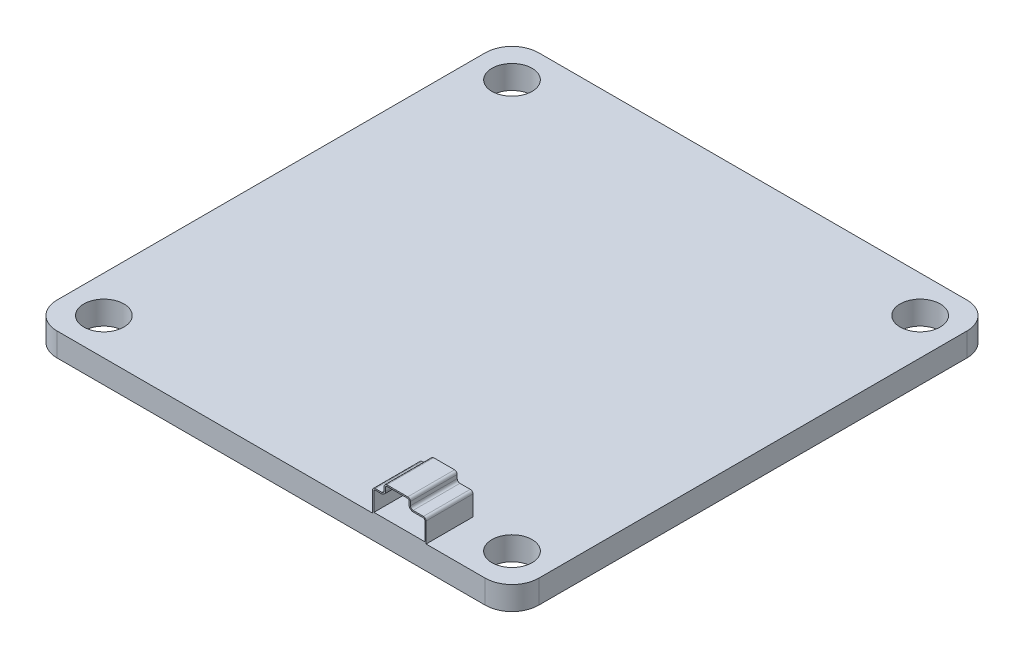
from build123d import *

# Parameters (mm, degrees)
SKETCH1_R           = 1.5
BOSS_EXTRUDE1_DEPTH = 1.75
BOSS_EXTRUDE4_DEPTH = 3
BOSS_EXTRUDE5_DEPTH = 0.5
CUT_EXTRUDE1_REACH  = 5.5
SKETCH7_R           = 0.25


with BuildPart() as part:
    # Sketch1 → Boss-Extrude1 (new body)
    with BuildSketch(Plane(origin=(0, 0, 0), x_dir=(1, 0, 0), z_dir=(0, 1, 0))):
        with BuildLine():
            Line((-16, 18), (16, 18))
            ThreePointArc((16, 18), (17.414213562, 17.414213562), (18, 16))
            Line((18, 16), (18, -16))
            ThreePointArc((18, -16), (17.414213562, -17.414213562), (16, -18))
            Line((16, -18), (-16, -18))
            ThreePointArc((-16, -18), (-17.414213562, -17.414213562), (-18, -16))
            Line((-18, -16), (-18, 16))
            ThreePointArc((-18, 16), (-17.414213562, 17.414213562), (-16, 18))
        make_face()
        with Locations((-15.25, 15.25)):
            Circle(SKETCH1_R, mode=Mode.SUBTRACT)
        with Locations((15.25, 15.25)):
            Circle(SKETCH1_R, mode=Mode.SUBTRACT)
        with Locations((15.25, -15.25)):
            Circle(SKETCH1_R, mode=Mode.SUBTRACT)
        with Locations((-15.25, -15.25)):
            Circle(SKETCH1_R, mode=Mode.SUBTRACT)
    extrude(amount=BOSS_EXTRUDE1_DEPTH)

    # Sketch2 → Boss-Extrude4 (add)
    with BuildSketch(Plane.XY.offset(18)):
        with BuildLine():
            Line((7.580760647, 1.75), (11.580760647, 1.75))
            Line((11.580760647, 1.75), (11.580760647, 3.240036049))
            ThreePointArc((11.580760647, 3.240036049), (11.522182003, 3.381457405), (11.380760647, 3.440036049))
            Line((11.380760647, 3.440036049), (10.607400333, 3.440036049))
            ThreePointArc((10.607400333, 3.440036049), (10.465978977, 3.498614693), (10.407400333, 3.640036049))
            Line((10.407400333, 3.640036049), (10.407400333, 3.917594602))
            ThreePointArc((10.407400333, 3.917594602), (10.348821689, 4.059015958), (10.207400333, 4.117594602))
            Line((10.207400333, 4.117594602), (8.648098096, 4.117594602))
            ThreePointArc((8.648098096, 4.117594602), (8.50667674, 4.059015958), (8.448098096, 3.917594602))
            Line((8.448098096, 3.917594602), (8.448098096, 3.640036049))
            ThreePointArc((8.448098096, 3.640036049), (8.389519452, 3.498614693), (8.248098096, 3.440036049))
            Line((8.248098096, 3.440036049), (7.780760647, 3.440036049))
            ThreePointArc((7.780760647, 3.440036049), (7.63933929, 3.381457405), (7.580760647, 3.240036049))
            Line((7.580760647, 3.240036049), (7.580760647, 1.75))
        make_face()
        with BuildLine():
            Line((8.648098096, 4.017594602), (10.207400333, 4.017594602))
            ThreePointArc((10.207400333, 4.017594602), (10.278111011, 3.98830528), (10.307400333, 3.917594602))
            Line((10.307400333, 3.917594602), (10.307400333, 3.640036049))
            ThreePointArc((10.307400333, 3.640036049), (10.395268299, 3.427904014), (10.607400333, 3.340036049))
            Line((10.607400333, 3.340036049), (11.380760647, 3.340036049))
            ThreePointArc((11.380760647, 3.340036049), (11.451471325, 3.310746727), (11.480760647, 3.240036049))
            Line((11.480760647, 3.240036049), (11.480760647, 1.85))
            Line((11.480760647, 1.85), (7.680760647, 1.85))
            Line((7.680760647, 1.85), (7.680760647, 3.240036049))
            ThreePointArc((7.680760647, 3.240036049), (7.710049968, 3.310746727), (7.780760647, 3.340036049))
            Line((7.780760647, 3.340036049), (8.248098096, 3.340036049))
            ThreePointArc((8.248098096, 3.340036049), (8.460230131, 3.427904014), (8.548098096, 3.640036049))
            Line((8.548098096, 3.640036049), (8.548098096, 3.917594602))
            ThreePointArc((8.548098096, 3.917594602), (8.577387418, 3.98830528), (8.648098096, 4.017594602))
        make_face(mode=Mode.SUBTRACT)
    extrude(amount=-BOSS_EXTRUDE4_DEPTH)

    # Sketch5 → Boss-Extrude5 (add)
    with BuildSketch(Plane(origin=(0, 0, 15), x_dir=(-1, 0, 0), z_dir=(0, 0, -1))):
        with BuildLine():
            Line((-7.580760647, 1.75), (-7.580760647, 3.240036049))
            ThreePointArc((-7.580760647, 3.240036049), (-7.63933929, 3.381457405), (-7.780760647, 3.440036049))
            Line((-7.780760647, 3.440036049), (-8.248098096, 3.440036049))
            ThreePointArc((-8.248098096, 3.440036049), (-8.389519452, 3.498614693), (-8.448098096, 3.640036049))
            Line((-8.448098096, 3.640036049), (-8.448098096, 3.917594602))
            ThreePointArc((-8.448098096, 3.917594602), (-8.50667674, 4.059015958), (-8.648098096, 4.117594602))
            Line((-8.648098096, 4.117594602), (-10.207400333, 4.117594602))
            ThreePointArc((-10.207400333, 4.117594602), (-10.348821689, 4.059015958), (-10.407400333, 3.917594602))
            Line((-10.407400333, 3.917594602), (-10.407400333, 3.640036049))
            ThreePointArc((-10.407400333, 3.640036049), (-10.465978977, 3.498614693), (-10.607400333, 3.440036049))
            Line((-10.607400333, 3.440036049), (-11.380760647, 3.440036049))
            ThreePointArc((-11.380760647, 3.440036049), (-11.522182003, 3.381457405), (-11.580760647, 3.240036049))
            Line((-11.580760647, 3.240036049), (-11.580760647, 1.75))
            Line((-11.580760647, 1.75), (-7.580760647, 1.75))
        make_face()
    extrude(amount=BOSS_EXTRUDE5_DEPTH)

    # Sketch7 → Cut-Extrude1 (cut, up to next)
    with BuildSketch(Plane(origin=(0, 0, 14.5), x_dir=(-1, 0, 0), z_dir=(0, 0, -1)), mode=Mode.PRIVATE) as cut_extrude1_sk1:
        with Locations((-10.302378592, 3.199328245)):
            Circle(SKETCH7_R)
    cut_extrude1_tool1 = extrude(cut_extrude1_sk1.sketch, amount=-CUT_EXTRUDE1_REACH, mode=Mode.PRIVATE) & part.part
    add(cut_extrude1_tool1.solids().sort_by_distance((10.302379, 3.199328, 14.5))[0], mode=Mode.SUBTRACT)
    # Sketch7 → Cut-Extrude1 (cut, up to next)
    with BuildSketch(Plane(origin=(0, 0, 14.5), x_dir=(-1, 0, 0), z_dir=(0, 0, -1)), mode=Mode.PRIVATE) as cut_extrude1_sk2:
        with Locations((-9.502378592, 3.199328245)):
            Circle(SKETCH7_R)
    cut_extrude1_tool2 = extrude(cut_extrude1_sk2.sketch, amount=-CUT_EXTRUDE1_REACH, mode=Mode.PRIVATE) & part.part
    add(cut_extrude1_tool2.solids().sort_by_distance((9.502379, 3.199328, 14.5))[0], mode=Mode.SUBTRACT)
    # Sketch7 → Cut-Extrude1 (cut, up to next)
    with BuildSketch(Plane(origin=(0, 0, 14.5), x_dir=(-1, 0, 0), z_dir=(0, 0, -1)), mode=Mode.PRIVATE) as cut_extrude1_sk3:
        with Locations((-8.702378592, 3.199328245)):
            Circle(SKETCH7_R)
    cut_extrude1_tool3 = extrude(cut_extrude1_sk3.sketch, amount=-CUT_EXTRUDE1_REACH, mode=Mode.PRIVATE) & part.part
    add(cut_extrude1_tool3.solids().sort_by_distance((8.702379, 3.199328, 14.5))[0], mode=Mode.SUBTRACT)


solid = part.part
